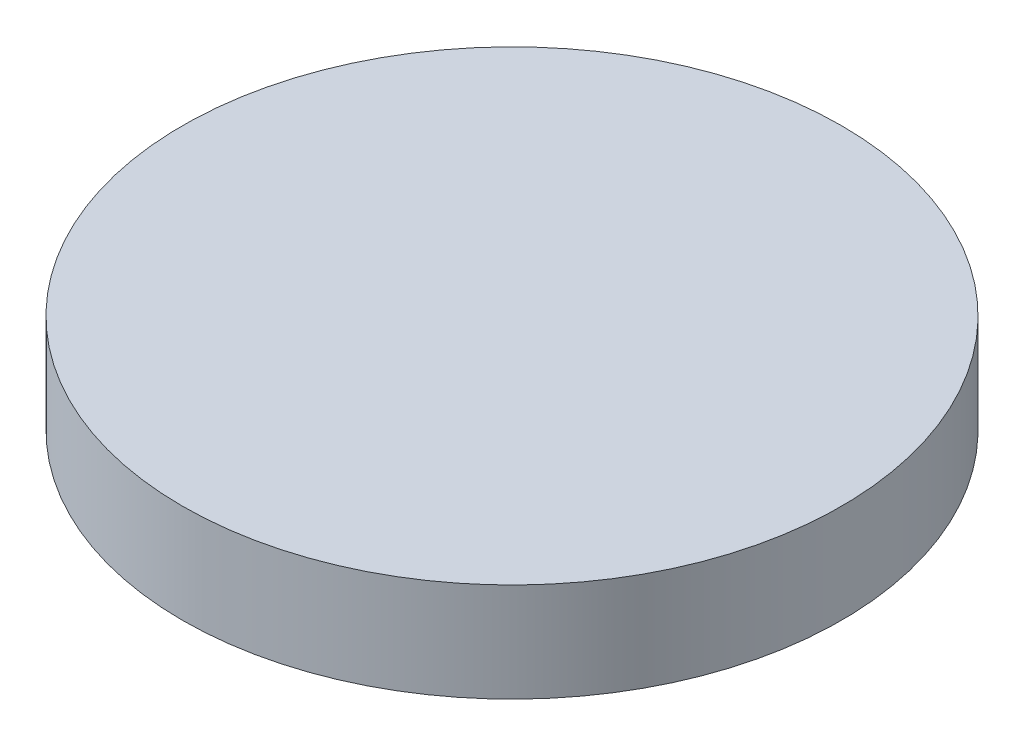
from build123d import *

# Parameters (mm, degrees)
SKETCH1_R           = 5
BOSS_EXTRUDE1_DEPTH = 1.5
SKETCH2_R           = 4.5
BOSS_EXTRUDE2_DEPTH = 0.1


with BuildPart() as part:
    # Sketch1 → Boss-Extrude1 (new body)
    with BuildSketch(Plane(origin=(0, 0, 0), x_dir=(1, 0, 0), z_dir=(0, 1, 0))):
        Circle(SKETCH1_R)
    extrude(amount=BOSS_EXTRUDE1_DEPTH)

    # Sketch2 → Boss-Extrude2 (add)
    with BuildSketch(Plane.XZ):
        Circle(SKETCH2_R)
    extrude(amount=BOSS_EXTRUDE2_DEPTH)


solid = part.part
